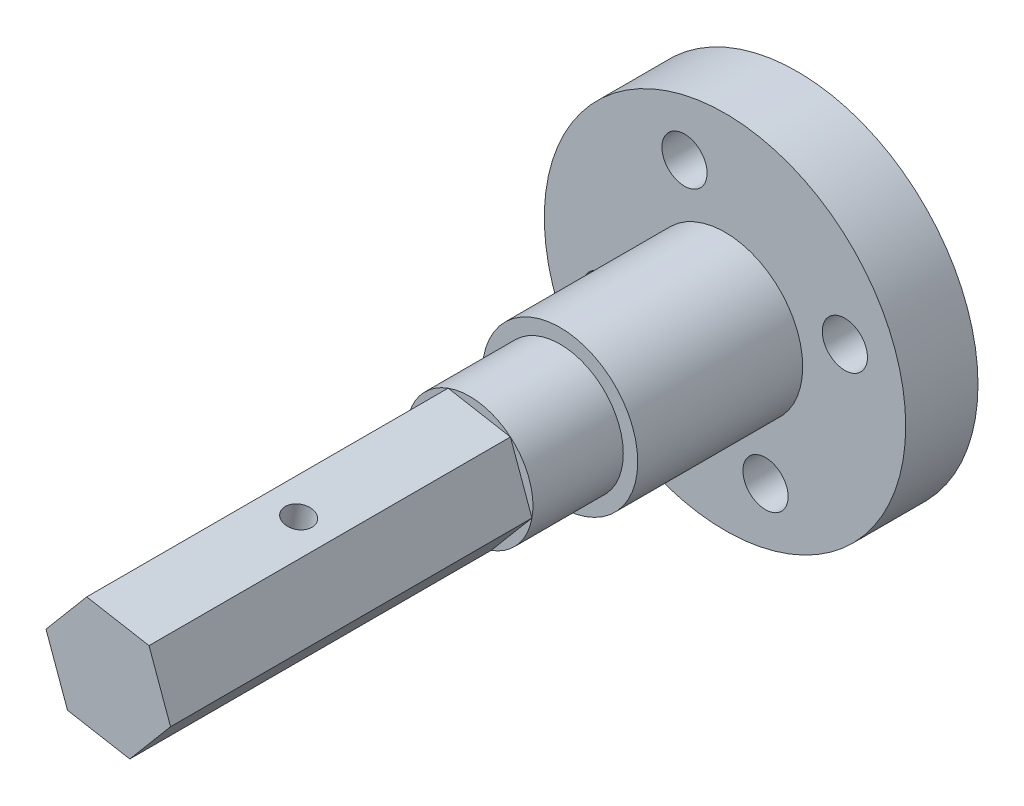
from build123d import *

# Parameters (mm, degrees)
ESQUISSE1_R             = 10
BOSS_EXTRU_1_DEPTH      = 4
ESQUISSE2_R             = 3.5
BOSS_EXTRU_2_DEPTH      = 14.13
BOSS_EXTRU_3_DEPTH      = 20
ESQUISSE4_R             = 1.25
ENL_V_MAT_EXTRU_1_DEPTH = 100
ESQUISSE5_R             = 0.75
ENL_V_MAT_EXTRU_2_DEPTH = 14
ESQUISSE6_R             = 2.127089322
ENL_V_MAT_EXTRU_3_DEPTH = 1.5
ESQUISSE7_R             = 4.3
ESQUISSE7_R_2           = 3.5
BOSS_EXTRU_4_DEPTH      = 9.13


with BuildPart() as part:
    # Esquisse1 → Boss.-Extru.1 (new body)
    with BuildSketch(Plane.XY):
        Circle(ESQUISSE1_R)
    extrude(amount=BOSS_EXTRU_1_DEPTH)

    # Esquisse2 → Boss.-Extru.2 (add)
    with BuildSketch(Plane.XY.offset(4)):
        Circle(ESQUISSE2_R)
    extrude(amount=BOSS_EXTRU_2_DEPTH)

    # Esquisse3 → Boss.-Extru.3 (add)
    with BuildSketch(Plane.XY.offset(18.13)):
        Polygon((-1.190476286, 3.29131679), (-3.445602095, 0.614675689), (-2.255125809, -2.676641101), (1.190476286, -3.29131679), (3.445602095, -0.614675689), (2.255125809, 2.676641101), align=None)
    extrude(amount=BOSS_EXTRU_3_DEPTH)

    # Esquisse4 → Enlèv. mat.-Extru.1 (cut)
    with BuildSketch(Plane(origin=(0, 0, 0), x_dir=(-1, 0, 0), z_dir=(0, 0, -1))):
        with Locations((2.241387648, 6.631453944)):
            Circle(ESQUISSE4_R)
        with Locations((-6.631453944, 2.241387648)):
            Circle(ESQUISSE4_R)
        with Locations((6.631453944, -2.241387648)):
            Circle(ESQUISSE4_R)
        with Locations((-2.241387648, -6.631453944)):
            Circle(ESQUISSE4_R)
    extrude(amount=-ENL_V_MAT_EXTRU_1_DEPTH, mode=Mode.SUBTRACT)

    # Esquisse5 → Enlèv. mat.-Extru.2 (cut)
    with BuildSketch(Plane(origin=(0.532324762, 2.983978946, 0), x_dir=(0.984457741, -0.175621625, 0), z_dir=(0.175621625, 0.984457741, 0))):
        with Locations((0, -28.127949192)):
            Circle(ESQUISSE5_R)
    extrude(amount=-ENL_V_MAT_EXTRU_2_DEPTH, mode=Mode.SUBTRACT)

    # Esquisse6 → Enlèv. mat.-Extru.3 (cut)
    with BuildSketch(Plane(origin=(0, 0, 0), x_dir=(-1, 0, 0), z_dir=(0, 0, -1))):
        Circle(ESQUISSE6_R)
    extrude(amount=-ENL_V_MAT_EXTRU_3_DEPTH, mode=Mode.SUBTRACT)

    # Esquisse7 → Boss.-Extru.4 (add)
    with BuildSketch(Plane.XY.offset(4)):
        Circle(ESQUISSE7_R)
        Circle(ESQUISSE7_R_2, mode=Mode.SUBTRACT)
    extrude(amount=BOSS_EXTRU_4_DEPTH)


solid = part.part
